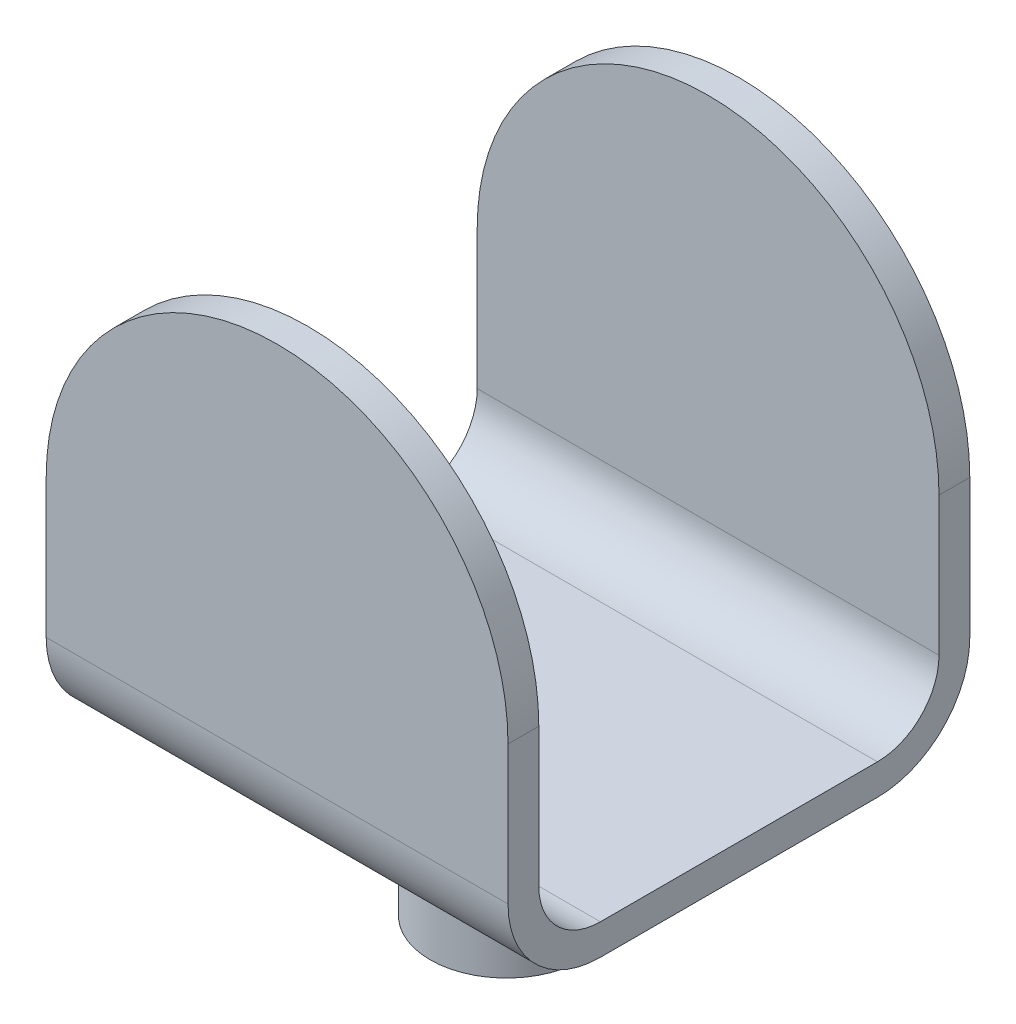
from build123d import *

# Parameters (mm, degrees)
SKETCH1_W           = 76.206980413
SKETCH1_H           = 76.206980413
BOSS_EXTRUDE1_DEPTH = 76.2
FILLET1_R           = 15.24
FILLET4_R           = 38.10349
CUT_EXTRUDE1_DEPTH  = 207.518
SKETCH4_R           = 12.615490026
BOSS_EXTRUDE2_DEPTH = 25.4


with BuildPart() as part:
    # Sketch1 → Boss-Extrude1 (new body)
    with BuildSketch(Plane.XY):
        with Locations((38.103490207, 38.103490207)):
            Rectangle(SKETCH1_W, SKETCH1_H)
    extrude(amount=BOSS_EXTRUDE1_DEPTH)

    # Fillet1
    fillet1_edges = [part.edges().sort_by_distance(p)[0] for p in [
        (38.103490206, 0, 76.2),
        (38.103490206, 0, 0),
    ]]
    fillet(fillet1_edges, radius=FILLET1_R)

    # Fillet4
    fillet4_edges = [part.edges().sort_by_distance(p)[0] for p in [
        (76.206980413, 76.206980413, 38.1),
        (0, 76.206980413, 38.1),
    ]]
    fillet(fillet4_edges, radius=FILLET4_R)

    # Sketch3 → Cut-Extrude1 (cut)
    with BuildSketch(Plane(origin=(76.206980413, 0, 0), x_dir=(0, 0, -1), z_dir=(1, 0, 0))):
        with BuildLine():
            Line((-71.12, 76.206980413), (-5.08, 76.206980413))
            Line((-5.08, 76.206980413), (-5.08, 38.103490206))
            Line((-5.08, 38.103490206), (-5.08, 15.24))
            ThreePointArc((-5.08, 15.24), (-8.055795103, 8.055795103), (-15.24, 5.08))
            Line((-15.24, 5.08), (-60.96, 5.08))
            ThreePointArc((-60.96, 5.08), (-68.144204897, 8.055795103), (-71.12, 15.24))
            Line((-71.12, 15.24), (-71.12, 38.103490206))
            Line((-71.12, 38.103490206), (-71.12, 76.206980413))
        make_face()
    extrude(amount=-CUT_EXTRUDE1_DEPTH, mode=Mode.SUBTRACT)

    # Sketch4 → Boss-Extrude2 (add)
    with BuildSketch(Plane(origin=(0, 0, 0), x_dir=(-1, 0, 0), z_dir=(0, -1, 0))):
        with Locations((-37.114040008, -37.351744978)):
            Circle(SKETCH4_R)
    extrude(amount=BOSS_EXTRUDE2_DEPTH)


solid = part.part
